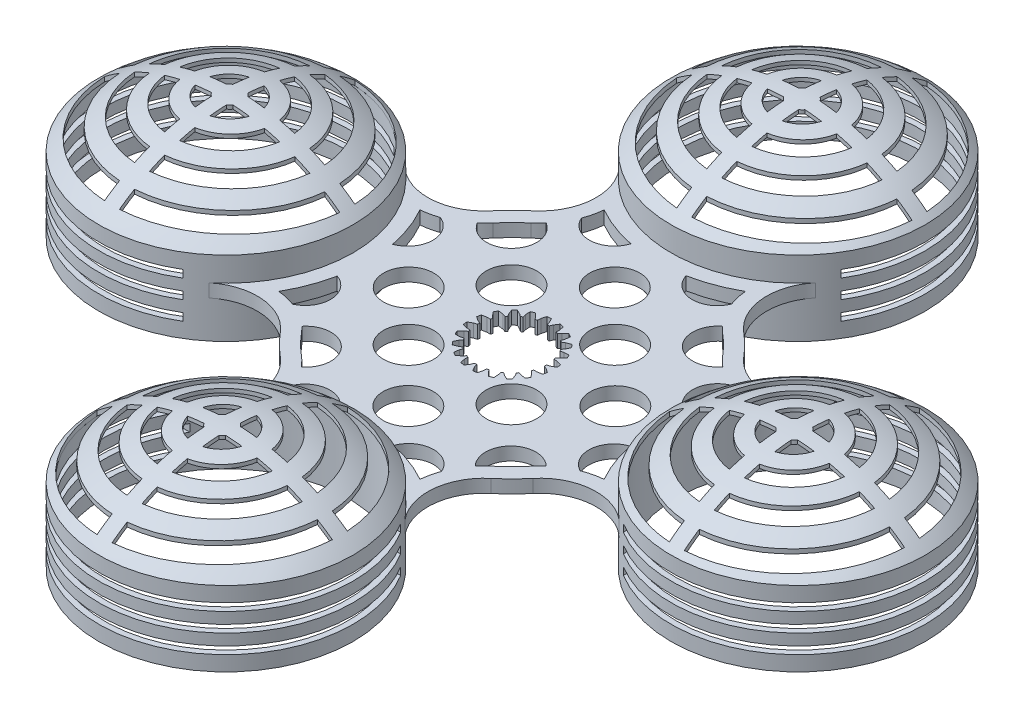
from build123d import *

# Parameters (mm, degrees)
IZIM1_R                     = 43.965787967
Y_KSEKLIK_EKSTR_ZYON1_DEPTH = 3.5
IZIM1_3_R                   = 34
IZIM1_3_R_2                 = 32.5
EKSTR_ZYON_NCE1_DEPTH       = 10
KES_EKSTR_ZYON1_DEPTH       = 14.5
DAIRESEL_KAPLAMA1_COUNT     = 4
RADYUS1_R                   = 15
KES_EKSTR_ZYON4_DEPTH       = 20.257302442
DAIRESEL_KAPLAMA2_COUNT     = 4
IZIM7_R                     = 6.70637008
KES_EKSTR_ZYON5_DEPTH       = 14.5000001
IZIM8_W                     = 51.647107597
IZIM8_H                     = 2
KES_EKSTR_ZYON6_DEPTH       = 111.465788067
DAIRESEL_KAPLAMA3_COUNT     = 4


with BuildPart() as part:
    # Çizim1 → Yükseklik-Ekstrüzyon1 (new body)
    with BuildSketch(Plane(origin=(0, 0, 0), x_dir=(1, 0, 0), z_dir=(0, 1, 0))):
        Circle(IZIM1_R)
    extrude(amount=Y_KSEKLIK_EKSTR_ZYON1_DEPTH)

    # Çizim1<3> → Ekstrüzyon-İnce1 (add, symmetric)
    with BuildSketch(Plane(origin=(0, 0, 0), x_dir=(1, 0, 0), z_dir=(0, 1, 0))):
        with Locations((76.465787967, 0)):
            Circle(IZIM1_3_R)
        with Locations((76.465787967, 0)):
            Circle(IZIM1_3_R_2, mode=Mode.SUBTRACT)
        with Locations((0, -76.465787967)):
            Circle(IZIM1_3_R)
        with Locations((0, -76.465787967)):
            Circle(IZIM1_3_R_2, mode=Mode.SUBTRACT)
        with Locations((-76.465787967, 0)):
            Circle(IZIM1_3_R)
        with Locations((-76.465787967, 0)):
            Circle(IZIM1_3_R_2, mode=Mode.SUBTRACT)
        with Locations((0, 76.465787967)):
            Circle(IZIM1_3_R)
        with Locations((0, 76.465787967)):
            Circle(IZIM1_3_R_2, mode=Mode.SUBTRACT)
    extrude(amount=EKSTR_ZYON_NCE1_DEPTH, both=True)

    # Çizim2 → Kes-Ekstrüzyon1 (cut, through all)
    with BuildSketch(Plane(origin=(0, 3.5, 0), x_dir=(1, 0, 0), z_dir=(0, 1, 0))):
        with BuildLine():
            Line((-2.997406538, -9.655669104), (-2.758338033, -10.958173721))
            ThreePointArc((-2.758338033, -10.958173721), (-2.23190166, -11.077392066), (-1.700372792, -11.171335299))
            Line((-1.700372792, -11.171335299), (-0.975568902, -10.06303419))
            Line((-0.975568902, -10.06303419), (-0.651778515, -9.277132357))
            ThreePointArc((-0.651778515, -9.277132357), (-0.388079408, -9.291899395), (-0.12406731, -9.299172399))
            Line((-0.12406731, -9.299172399), (0.133062825, -10.10933658))
            Line((0.133062825, -10.10933658), (0.762926547, -11.274215852))
            ThreePointArc((0.762926547, -11.274215852), (1.300437784, -11.22492145), (1.834981833, -11.150015322))
            Line((1.834981833, -11.150015322), (2.181827419, -9.87198161))
            Line((2.181827419, -9.87198161), (2.246913353, -9.024487818))
            ThreePointArc((2.246913353, -9.024487818), (2.502269373, -8.957044601), (2.755607282, -8.882377413))
            Line((2.755607282, -8.882377413), (3.250507072, -9.573431755))
            Line((3.250507072, -9.573431755), (4.20951056, -10.486659184))
            ThreePointArc((4.20951056, -10.486659184), (4.705481317, -10.273677315), (5.190715652, -10.037254157))
            Line((5.190715652, -10.037254157), (5.12565127, -8.714590688))
            Line((5.12565127, -8.714590688), (4.925661688, -7.888463535))
            ThreePointArc((4.925661688, -7.888463535), (5.147678594, -7.745411874), (5.365543833, -7.596113439))
            Line((5.365543833, -7.596113439), (6.049769039, -8.100412729))
            Line((6.049769039, -8.100412729), (7.244038351, -8.67259525))
            ThreePointArc((7.244038351, -8.67259525), (7.649919554, -8.316774063), (8.038346056, -7.941976623))
            Line((8.038346056, -7.941976623), (7.567740662, -6.704154911))
            Line((7.567740662, -6.704154911), (7.122251937, -5.980261478))
            ThreePointArc((7.122251937, -5.980261478), (7.289197168, -5.775604267), (7.450263569, -5.566288957))
            Line((7.450263569, -5.566288957), (8.256837461, -5.834468865))
            Line((8.256837461, -5.834468865), (9.569469195, -6.009597268))
            ThreePointArc((9.569469195, -6.009597268), (9.845530365, -5.545767019), (10.099127143, -5.069283081))
            Line((10.099127143, -5.069283081), (9.269046871, -4.037469741))
            Line((9.269046871, -4.037469741), (8.621666543, -3.486669761))
            ThreePointArc((8.621666543, -3.486669761), (8.717198337, -3.240440273), (8.805699599, -2.991597328))
            Line((8.805699599, -2.991597328), (9.655669104, -2.997406538))
            Line((9.655669104, -2.997406538), (10.958173721, -2.758338033))
            ThreePointArc((10.958173721, -2.758338033), (11.077392066, -2.23190166), (11.171335299, -1.700372792))
            Line((11.171335299, -1.700372792), (10.06303419, -0.975568902))
            Line((10.06303419, -0.975568902), (9.277132357, -0.651778515))
            ThreePointArc((9.277132357, -0.651778515), (9.291899395, -0.388079408), (9.299172399, -0.12406731))
            Line((9.299172399, -0.12406731), (10.10933658, 0.133062825))
            Line((10.10933658, 0.133062825), (11.274215852, 0.762926547))
            ThreePointArc((11.274215852, 0.762926547), (11.22492145, 1.300437784), (11.150015322, 1.834981833))
            Line((11.150015322, 1.834981833), (9.87198161, 2.181827419))
            Line((9.87198161, 2.181827419), (9.024487818, 2.246913353))
            ThreePointArc((9.024487818, 2.246913353), (8.957044601, 2.502269373), (8.882377413, 2.755607282))
            Line((8.882377413, 2.755607282), (9.573431755, 3.250507072))
            Line((9.573431755, 3.250507072), (10.486659184, 4.20951056))
            ThreePointArc((10.486659184, 4.20951056), (10.273677315, 4.705481317), (10.037254157, 5.190715652))
            Line((10.037254157, 5.190715652), (8.714590688, 5.12565127))
            Line((8.714590688, 5.12565127), (7.888463535, 4.925661688))
            ThreePointArc((7.888463535, 4.925661688), (7.745411874, 5.147678594), (7.596113439, 5.365543833))
            Line((7.596113439, 5.365543833), (8.100412729, 6.049769039))
            Line((8.100412729, 6.049769039), (8.67259525, 7.244038351))
            ThreePointArc((8.67259525, 7.244038351), (8.316774063, 7.649919554), (7.941976623, 8.038346056))
            Line((7.941976623, 8.038346056), (6.704154911, 7.567740662))
            Line((6.704154911, 7.567740662), (5.980261478, 7.122251937))
            ThreePointArc((5.980261478, 7.122251937), (5.775604267, 7.289197168), (5.566288957, 7.450263569))
            Line((5.566288957, 7.450263569), (5.834468865, 8.256837461))
            Line((5.834468865, 8.256837461), (6.009597268, 9.569469195))
            ThreePointArc((6.009597268, 9.569469195), (5.545767019, 9.845530365), (5.069283081, 10.099127143))
            Line((5.069283081, 10.099127143), (4.037469741, 9.269046871))
            Line((4.037469741, 9.269046871), (3.486669761, 8.621666543))
            ThreePointArc((3.486669761, 8.621666543), (3.240440273, 8.717198337), (2.991597328, 8.805699599))
            Line((2.991597328, 8.805699599), (2.997406538, 9.655669104))
            Line((2.997406538, 9.655669104), (2.758338033, 10.958173721))
            ThreePointArc((2.758338033, 10.958173721), (2.23190166, 11.077392066), (1.700372792, 11.171335299))
            Line((1.700372792, 11.171335299), (0.975568902, 10.06303419))
            Line((0.975568902, 10.06303419), (0.651778515, 9.277132357))
            ThreePointArc((0.651778515, 9.277132357), (0.388079408, 9.291899395), (0.12406731, 9.299172399))
            Line((0.12406731, 9.299172399), (-0.133062825, 10.10933658))
            Line((-0.133062825, 10.10933658), (-0.762926547, 11.274215852))
            ThreePointArc((-0.762926547, 11.274215852), (-1.300437784, 11.22492145), (-1.834981833, 11.150015322))
            Line((-1.834981833, 11.150015322), (-2.181827419, 9.87198161))
            Line((-2.181827419, 9.87198161), (-2.246913353, 9.024487818))
            ThreePointArc((-2.246913353, 9.024487818), (-2.502269373, 8.957044601), (-2.755607282, 8.882377413))
            Line((-2.755607282, 8.882377413), (-3.250507072, 9.573431755))
            Line((-3.250507072, 9.573431755), (-4.20951056, 10.486659184))
            ThreePointArc((-4.20951056, 10.486659184), (-4.705481317, 10.273677315), (-5.190715652, 10.037254157))
            Line((-5.190715652, 10.037254157), (-5.12565127, 8.714590688))
            Line((-5.12565127, 8.714590688), (-4.925661688, 7.888463535))
            ThreePointArc((-4.925661688, 7.888463535), (-5.147678594, 7.745411874), (-5.365543833, 7.596113439))
            Line((-5.365543833, 7.596113439), (-6.049769039, 8.100412729))
            Line((-6.049769039, 8.100412729), (-7.244038351, 8.67259525))
            ThreePointArc((-7.244038351, 8.67259525), (-7.649919554, 8.316774063), (-8.038346056, 7.941976623))
            Line((-8.038346056, 7.941976623), (-7.567740662, 6.704154911))
            Line((-7.567740662, 6.704154911), (-7.122251937, 5.980261478))
            ThreePointArc((-7.122251937, 5.980261478), (-7.289197168, 5.775604267), (-7.450263569, 5.566288957))
            Line((-7.450263569, 5.566288957), (-8.256837461, 5.834468865))
            Line((-8.256837461, 5.834468865), (-9.569469195, 6.009597268))
            ThreePointArc((-9.569469195, 6.009597268), (-9.845530365, 5.545767019), (-10.099127143, 5.069283081))
            Line((-10.099127143, 5.069283081), (-9.269046871, 4.037469741))
            Line((-9.269046871, 4.037469741), (-8.621666543, 3.486669761))
            ThreePointArc((-8.621666543, 3.486669761), (-8.717198336, 3.240440273), (-8.805699599, 2.991597328))
            Line((-8.805699599, 2.991597328), (-9.655669104, 2.997406538))
            Line((-9.655669104, 2.997406538), (-10.958173721, 2.758338033))
            ThreePointArc((-10.958173721, 2.758338033), (-11.077392066, 2.23190166), (-11.171335299, 1.700372792))
            Line((-11.171335299, 1.700372792), (-10.06303419, 0.975568902))
            Line((-10.06303419, 0.975568902), (-9.277132357, 0.651778515))
            ThreePointArc((-9.277132357, 0.651778515), (-9.291899395, 0.388079408), (-9.299172399, 0.12406731))
            Line((-9.299172399, 0.12406731), (-10.10933658, -0.133062825))
            Line((-10.10933658, -0.133062825), (-11.274215852, -0.762926547))
            ThreePointArc((-11.274215852, -0.762926547), (-11.22492145, -1.300437784), (-11.150015322, -1.834981833))
            Line((-11.150015322, -1.834981833), (-9.87198161, -2.181827419))
            Line((-9.87198161, -2.181827419), (-9.024487818, -2.246913353))
            ThreePointArc((-9.024487818, -2.246913353), (-8.957044601, -2.502269373), (-8.882377413, -2.755607282))
            Line((-8.882377413, -2.755607282), (-9.573431755, -3.250507072))
            Line((-9.573431755, -3.250507072), (-10.486659184, -4.20951056))
            ThreePointArc((-10.486659184, -4.20951056), (-10.273677315, -4.705481317), (-10.037254157, -5.190715652))
            Line((-10.037254157, -5.190715652), (-8.714590688, -5.12565127))
            Line((-8.714590688, -5.12565127), (-7.888463535, -4.925661688))
            ThreePointArc((-7.888463535, -4.925661688), (-7.745411874, -5.147678594), (-7.596113439, -5.365543833))
            Line((-7.596113439, -5.365543833), (-8.100412729, -6.049769039))
            Line((-8.100412729, -6.049769039), (-8.67259525, -7.244038351))
            ThreePointArc((-8.67259525, -7.244038351), (-8.316774063, -7.649919554), (-7.941976623, -8.038346056))
            Line((-7.941976623, -8.038346056), (-6.704154911, -7.567740662))
            Line((-6.704154911, -7.567740662), (-5.980261478, -7.122251937))
            ThreePointArc((-5.980261478, -7.122251937), (-5.775604267, -7.289197168), (-5.566288957, -7.450263569))
            Line((-5.566288957, -7.450263569), (-5.834468865, -8.256837461))
            Line((-5.834468865, -8.256837461), (-6.009597268, -9.569469195))
            ThreePointArc((-6.009597268, -9.569469195), (-5.545767019, -9.845530365), (-5.069283081, -10.099127143))
            Line((-5.069283081, -10.099127143), (-4.037469741, -9.269046871))
            Line((-4.037469741, -9.269046871), (-3.486669761, -8.621666543))
            ThreePointArc((-3.486669761, -8.621666543), (-3.240440273, -8.717198336), (-2.991597328, -8.805699599))
            Line((-2.991597328, -8.805699599), (-2.997406538, -9.655669104))
        make_face()
    extrude(amount=-KES_EKSTR_ZYON1_DEPTH, mode=Mode.SUBTRACT)

    # Çizim4 one side → Döndür5 (revolve)
    with BuildSketch(Plane(origin=(6.242130058, 0, -20.936695197), x_dir=(-0.958314677, 0, -0.285714856), z_dir=(0.285714856, 0, -0.958314677))):
        with BuildLine():
            Line((-40.778286934, 10), (-39.278286934, 10))
            ThreePointArc((-39.278286934, 10), (-55.120996624, 19.462992187), (-73.278286934, 22.757302442))
            Line((-73.278286934, 22.757302442), (-73.278286934, 21.783161652))
            ThreePointArc((-73.278286934, 21.783161652), (-55.993229091, 18.746449569), (-40.778286934, 10))
        make_face()
    d_nd_r5 = revolve(axis=Axis((76.465787967, 30.969310769, 0), (0, -1, 0)))

    # Dairesel Kaplama1: Döndür5 ×4 about axis
    dairesel_kaplama1_axis = Axis((0, 0, 0), (0, 1, 0))
    for i in range(1, DAIRESEL_KAPLAMA1_COUNT):
        add(d_nd_r5.rotate(dairesel_kaplama1_axis, i * 360 / DAIRESEL_KAPLAMA1_COUNT))

    # Radyus1
    radyus1_edges = [part.edges().sort_by_distance(p)[0] for p in [
        (-7.545074908, 1.75, 43.313535485),
        (7.545074908, 1.75, 43.313535485),
        (43.313535485, 1.75, 7.545074908),
        (43.313535485, 1.75, -7.545074908),
        (7.545074908, 1.75, -43.313535485),
        (-7.545074908, 1.75, -43.313535485),
        (-43.313535485, 1.75, -7.545074908),
        (-43.313535485, 1.75, 7.545074908),
    ]]
    fillet(radyus1_edges, radius=RADYUS1_R)

    # Çizim6 → Kes-Ekstrüzyon4 (cut, through all)
    with BuildSketch(Plane(origin=(0, 3.5, 0), x_dir=(1, 0, 0), z_dir=(0, 1, 0))):
        with BuildLine():
            ThreePointArc((32.428868648, 78.459347515), (23.266288436, 98.733211122), (2.992424829, 107.895791334))
            Line((2.992424829, 107.895791334), (2.992424829, 103.886523819))
            ThreePointArc((2.992424829, 103.886523819), (20.437861312, 95.904783997), (28.419601133, 78.459347515))
            Line((28.419601133, 78.459347515), (32.428868648, 78.459347515))
        make_face()
        with BuildLine():
            ThreePointArc((24.407163777, 78.459347515), (17.609434187, 93.076356873), (2.992424829, 99.874086463))
            Line((2.992424829, 99.874086463), (2.992424829, 95.856512256))
            ThreePointArc((2.992424829, 95.856512256), (14.781007062, 90.247929748), (20.38958957, 78.459347515))
            Line((20.38958957, 78.459347515), (24.407163777, 78.459347515))
        make_face()
        with BuildLine():
            ThreePointArc((16.362850978, 78.459347515), (11.952579937, 87.419502623), (2.992424829, 91.829773664))
            Line((2.992424829, 91.829773664), (2.992424829, 87.784099168))
            ThreePointArc((2.992424829, 87.784099168), (9.124152813, 84.591075499), (12.317176482, 78.459347515))
            Line((12.317176482, 78.459347515), (16.362850978, 78.459347515))
        make_face()
        with BuildLine():
            ThreePointArc((8.220840977, 78.459347515), (6.295725688, 81.762648374), (2.992424829, 83.687763662))
            Line((2.992424829, 83.687763662), (2.992424829, 79.331628838))
            ThreePointArc((2.992424829, 79.331628838), (3.467298563, 78.934221249), (3.864706152, 78.459347515))
            Line((3.864706152, 78.459347515), (8.220840977, 78.459347515))
        make_face()
        with BuildLine():
            Line((2.992424829, 73.587066192), (2.992424829, 69.230931367))
            ThreePointArc((2.992424829, 69.230931367), (6.295725688, 71.156046656), (8.220840977, 74.459347515))
            Line((8.220840977, 74.459347515), (3.864706152, 74.459347515))
            ThreePointArc((3.864706152, 74.459347515), (3.467298563, 73.984473781), (2.992424829, 73.587066192))
        make_face()
        with BuildLine():
            Line((-1.879856494, 74.459347515), (-6.235991318, 74.459347515))
            ThreePointArc((-6.235991318, 74.459347515), (-4.31087603, 71.156046656), (-1.007575171, 69.230931367))
            Line((-1.007575171, 69.230931367), (-1.007575171, 73.587066192))
            ThreePointArc((-1.007575171, 73.587066192), (-1.482448905, 73.984473781), (-1.879856494, 74.459347515))
        make_face()
        with BuildLine():
            ThreePointArc((-1.007575171, 83.687763662), (-4.31087603, 81.762648374), (-6.235991318, 78.459347515))
            Line((-6.235991318, 78.459347515), (-1.879856494, 78.459347515))
            ThreePointArc((-1.879856494, 78.459347515), (-1.482448905, 78.934221249), (-1.007575171, 79.331628838))
            Line((-1.007575171, 79.331628838), (-1.007575171, 83.687763662))
        make_face()
        with BuildLine():
            ThreePointArc((-1.007575171, 91.829773664), (-9.967730279, 87.419502623), (-14.37800132, 78.459347515))
            Line((-14.37800132, 78.459347515), (-10.332326824, 78.459347515))
            ThreePointArc((-10.332326824, 78.459347515), (-7.139303155, 84.591075499), (-1.007575171, 87.784099168))
            Line((-1.007575171, 87.784099168), (-1.007575171, 91.829773664))
        make_face()
        with BuildLine():
            ThreePointArc((-1.007575171, 99.874086463), (-15.624584529, 93.076356873), (-22.422314119, 78.459347515))
            Line((-22.422314119, 78.459347515), (-18.404739912, 78.459347515))
            ThreePointArc((-18.404739912, 78.459347515), (-12.796157404, 90.247929748), (-1.007575171, 95.856512256))
            Line((-1.007575171, 95.856512256), (-1.007575171, 99.874086463))
        make_face()
        with BuildLine():
            ThreePointArc((-1.007575171, 107.895791334), (-21.281438778, 98.733211122), (-30.44401899, 78.459347515))
            Line((-30.44401899, 78.459347515), (-26.434751475, 78.459347515))
            ThreePointArc((-26.434751475, 78.459347515), (-18.453011654, 95.904783997), (-1.007575171, 103.886523819))
            Line((-1.007575171, 103.886523819), (-1.007575171, 107.895791334))
        make_face()
        with BuildLine():
            Line((-26.434751475, 74.459347515), (-30.44401899, 74.459347515))
            ThreePointArc((-30.44401899, 74.459347515), (-21.281438778, 54.185483907), (-1.007575171, 45.022903696))
            Line((-1.007575171, 45.022903696), (-1.007575171, 49.032171211))
            ThreePointArc((-1.007575171, 49.032171211), (-18.453011654, 57.013911032), (-26.434751475, 74.459347515))
        make_face()
        with BuildLine():
            Line((-18.404739912, 74.459347515), (-22.422314119, 74.459347515))
            ThreePointArc((-22.422314119, 74.459347515), (-15.624584529, 59.842338157), (-1.007575171, 53.044608567))
            Line((-1.007575171, 53.044608567), (-1.007575171, 57.062182774))
            ThreePointArc((-1.007575171, 57.062182774), (-12.796157404, 62.670765282), (-18.404739912, 74.459347515))
        make_face()
        with BuildLine():
            Line((-10.332326824, 74.459347515), (-14.37800132, 74.459347515))
            ThreePointArc((-14.37800132, 74.459347515), (-9.967730279, 65.499192406), (-1.007575171, 61.088921366))
            Line((-1.007575171, 61.088921366), (-1.007575171, 65.134595862))
            ThreePointArc((-1.007575171, 65.134595862), (-7.139303155, 68.327619531), (-10.332326824, 74.459347515))
        make_face()
        with BuildLine():
            Line((2.992424829, 65.134595862), (2.992424829, 61.088921366))
            ThreePointArc((2.992424829, 61.088921366), (11.952579937, 65.499192406), (16.362850978, 74.459347515))
            Line((16.362850978, 74.459347515), (12.317176482, 74.459347515))
            ThreePointArc((12.317176482, 74.459347515), (9.124152813, 68.327619531), (2.992424829, 65.134595862))
        make_face()
        with BuildLine():
            Line((2.992424829, 57.062182774), (2.992424829, 53.044608567))
            ThreePointArc((2.992424829, 53.044608567), (17.609434187, 59.842338157), (24.407163777, 74.459347515))
            Line((24.407163777, 74.459347515), (20.38958957, 74.459347515))
            ThreePointArc((20.38958957, 74.459347515), (14.781007062, 62.670765282), (2.992424829, 57.062182774))
        make_face()
        with BuildLine():
            Line((2.992424829, 49.032171211), (2.992424829, 45.022903696))
            ThreePointArc((2.992424829, 45.022903696), (23.266288436, 54.185483907), (32.428868648, 74.459347515))
            Line((32.428868648, 74.459347515), (28.419601133, 74.459347515))
            ThreePointArc((28.419601133, 74.459347515), (20.437861312, 57.013911032), (2.992424829, 49.032171211))
        make_face()
    kes_ekstr_zyon4 = extrude(amount=KES_EKSTR_ZYON4_DEPTH, mode=Mode.SUBTRACT)

    # Dairesel Kaplama2: Kes-Ekstrüzyon4 ×4 about axis
    dairesel_kaplama2_axis = Axis((0, 0, 0), (0, 1, 0))
    for i in range(1, DAIRESEL_KAPLAMA2_COUNT):
        add(kes_ekstr_zyon4.rotate(dairesel_kaplama2_axis, i * 360 / DAIRESEL_KAPLAMA2_COUNT), mode=Mode.SUBTRACT)

    # Çizim7 → Kes-Ekstrüzyon5 (cut, through all)
    with BuildSketch(Plane(origin=(0, 3.5, 0), x_dir=(1, 0, 0), z_dir=(0, 1, 0))):
        with Locations((-27.024253061, -0.596571329)):
            Circle(IZIM7_R)
        with Locations((-13.804461776, 13.652066352)):
            Circle(IZIM7_R)
        with Locations((0.514644324, 26.940392163)):
            Circle(IZIM7_R)
        with Locations((13.825263985, 13.725965521)):
            Circle(IZIM7_R)
        with Locations((28.063642738, -0.454438241)):
            Circle(IZIM7_R)
        with BuildLine():
            ThreePointArc((43.481813683, -18.869484371), (40.93228502, -13.467374217), (39.26082983, -7.732469853))
            ThreePointArc((39.26082983, -7.732469853), (34.647990566, -13.60197618), (38.321193202, -20.100974026))
            ThreePointArc((38.321193202, -20.100974026), (40.858307051, -19.304212506), (43.481813683, -18.869484371))
        make_face()
        with Locations((13.741351803, -13.900575404)):
            Circle(IZIM7_R)
        with BuildLine():
            ThreePointArc((30.682040708, -25.61008758), (31.644273541, -24.542149543), (32.684492109, -23.550015979))
            ThreePointArc((32.684492109, -23.550015979), (23.273449826, -23.647699244), (23.227415952, -33.059135891))
            ThreePointArc((23.227415952, -33.059135891), (24.366013214, -31.817726027), (25.61008758, -30.682040708))
            ThreePointArc((25.61008758, -30.682040708), (28.260079687, -28.260079687), (30.682040708, -25.61008758))
        make_face()
        with BuildLine():
            ThreePointArc((18.869484371, -43.481813683), (19.251602911, -41.084905449), (19.936174, -38.756269348))
            ThreePointArc((19.936174, -38.756269348), (13.557249034, -34.764403589), (7.486170503, -39.21048967))
            ThreePointArc((7.486170503, -39.21048967), (13.3497636, -40.887932329), (18.869484371, -43.481813683))
        make_face()
        with Locations((0.354399219, -28.071076969)):
            Circle(IZIM7_R)
        with Locations((-13.76820244, -13.882700316)):
            Circle(IZIM7_R)
        with BuildLine():
            ThreePointArc((-25.61008758, -30.682040708), (-24.235429349, -31.949281485), (-22.99197525, -33.345492909))
            ThreePointArc((-22.99197525, -33.345492909), (-21.058081264, -30.990644041), (-20.365809661, -28.023150289))
            ThreePointArc((-20.365809661, -28.023150289), (-24.872182184, -21.687898881), (-32.335149236, -23.866643132))
            ThreePointArc((-32.335149236, -23.866643132), (-31.481009771, -24.712209472), (-30.682040708, -25.61008758))
            ThreePointArc((-30.682040708, -25.61008758), (-28.260079687, -28.260079687), (-25.61008758, -30.682040708))
        make_face()
        with BuildLine():
            ThreePointArc((-18.869484371, -43.481813683), (-13.370650577, -40.895776677), (-7.529913687, -39.219306256))
            ThreePointArc((-7.529913687, -39.219306256), (-13.583922769, -34.859790557), (-19.922294774, -38.794437098))
            ThreePointArc((-19.922294774, -38.794437098), (-19.247142247, -41.104715928), (-18.869484371, -43.481813683))
        make_face()
        with BuildLine():
            ThreePointArc((-43.481813683, -18.869484371), (-41.044465555, -19.260777734), (-38.678420017, -19.964769856))
            ThreePointArc((-38.678420017, -19.964769856), (-35.782377137, -17.49073384), (-34.700725036, -13.838618384))
            ThreePointArc((-34.700725036, -13.838618384), (-35.944200001, -9.948608536), (-39.213502123, -7.501146536))
            ThreePointArc((-39.213502123, -7.501146536), (-40.890616351, -13.356914483), (-43.481813683, -18.869484371))
        make_face()
        with BuildLine():
            ThreePointArc((-34.730740351, 13.576583469), (-35.910149865, 17.375018218), (-39.033546898, 19.837436605))
            ThreePointArc((-39.033546898, 19.837436605), (-41.228585589, 19.219754516), (-43.481813683, 18.869484371))
            ThreePointArc((-43.481813683, 18.869484371), (-40.848687422, 13.244702668), (-39.166950231, 7.266134015))
            ThreePointArc((-39.166950231, 7.266134015), (-35.950766745, 9.719715231), (-34.730740351, 13.576583469))
        make_face()
        with BuildLine():
            ThreePointArc((-20.346560593, 26.963930306), (-21.202265275, 30.241904383), (-23.551010668, 32.683366985))
            ThreePointArc((-23.551010668, 32.683366985), (-24.542687985, 31.64375018), (-25.61008758, 30.682040708))
            ThreePointArc((-25.61008758, 30.682040708), (-28.260079687, 28.260079687), (-30.682040708, 25.61008758))
            ThreePointArc((-30.682040708, 25.61008758), (-31.687101737, 24.49823105), (-32.776674814, 23.469055106))
            ThreePointArc((-32.776674814, 23.469055106), (-25.237737405, 20.507888713), (-20.346560593, 26.963930306))
        make_face()
        with BuildLine():
            ThreePointArc((-20.010428482, 38.556242994), (-13.507067812, 34.515220018), (-7.454106865, 39.204061077))
            ThreePointArc((-7.454106865, 39.204061077), (-13.334453709, 40.882191405), (-18.869484371, 43.481813683))
            ThreePointArc((-18.869484371, 43.481813683), (-19.275385227, 40.98090757), (-20.010428482, 38.556242994))
        make_face()
        with BuildLine():
            ThreePointArc((7.29980052, 39.173524529), (13.468299604, 34.487017808), (19.940612538, 38.744116759))
            ThreePointArc((19.940612538, 38.744116759), (19.25302836, 41.078595567), (18.869484371, 43.481813683))
            ThreePointArc((18.869484371, 43.481813683), (13.260777005, 40.854669012), (7.29980052, 39.173524529))
        make_face()
        with BuildLine():
            ThreePointArc((23.857751829, 32.344724514), (23.248003819, 22.26227175), (33.321035792, 23.011720384))
            ThreePointArc((33.321035792, 23.011720384), (31.93807788, 24.24645135), (30.682040708, 25.61008758))
            ThreePointArc((30.682040708, 25.61008758), (28.260079687, 28.260079687), (25.61008758, 30.682040708))
            ThreePointArc((25.61008758, 30.682040708), (24.707469241, 31.485505938), (23.857751829, 32.344724514))
        make_face()
        with BuildLine():
            ThreePointArc((39.178358726, 7.324453603), (40.859054444, 13.272547901), (43.481813683, 18.869484371))
            ThreePointArc((43.481813683, 18.869484371), (41.097308668, 19.248807513), (38.780163544, 19.927474362))
            ThreePointArc((38.780163544, 19.927474362), (34.561299201, 13.486377514), (39.178358726, 7.324453603))
        make_face()
    extrude(amount=-KES_EKSTR_ZYON5_DEPTH, mode=Mode.SUBTRACT)

    # Çizim8 → Kes-Ekstrüzyon6 (cut, symmetric)
    with BuildSketch(Plane.XY):
        with Locations((84.642234169, 5)):
            Rectangle(IZIM8_W, IZIM8_H)
        with Locations((84.642234169, 0)):
            Rectangle(IZIM8_W, IZIM8_H)
        with Locations((84.642234169, -5)):
            Rectangle(IZIM8_W, IZIM8_H)
    kes_ekstr_zyon6 = extrude(amount=KES_EKSTR_ZYON6_DEPTH, both=True, mode=Mode.SUBTRACT)

    # Dairesel Kaplama3: Kes-Ekstrüzyon6 ×4 about axis
    dairesel_kaplama3_axis = Axis((0, 0, 0), (0, 1, 0))
    for i in range(1, DAIRESEL_KAPLAMA3_COUNT):
        add(kes_ekstr_zyon6.rotate(dairesel_kaplama3_axis, i * 360 / DAIRESEL_KAPLAMA3_COUNT), mode=Mode.SUBTRACT)


solid = part.part
